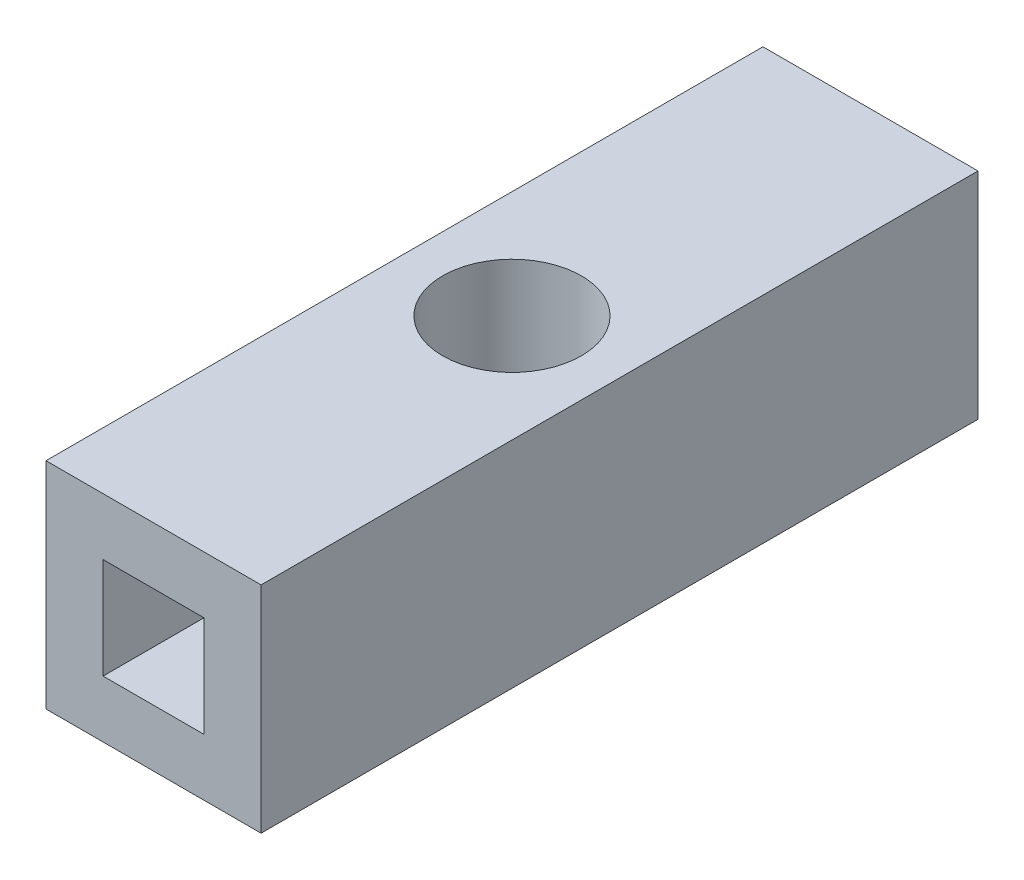
from build123d import *

# Parameters (mm, degrees)
SKETCH2_W               = 7.62
SKETCH2_H               = 7.62
BOSS_EXTRUDE1_DEPTH     = 12.7
F_8_CLEARANCE_HOLE1_D   = 4.9149
CUT_EXTRUDE1_REACH      = 27.965
CUT_EXTRUDE1_END_RADIUS = 3.47345
SKETCH5_W               = 3.175
SKETCH5_H               = 3.175
CUT_EXTRUDE2_REACH      = 27.965
CUT_EXTRUDE2_END_RADIUS = 3.47345
CUT_EXTRUDE3_REACH      = 27.965
CUT_EXTRUDE3_END_RADIUS = 3.47345
SKETCH7_W               = 3.575
SKETCH7_H               = 3.575
SKETCH7_W_2             = 3.175
SKETCH7_H_2             = 3.175
CUT_EXTRUDE4_REACH      = 27.965
CUT_EXTRUDE4_END_RADIUS = 3.47345


with BuildPart() as part:
    # Sketch2 → Boss-Extrude1 (new, symmetric)
    with BuildSketch(Plane.XY):
        Rectangle(SKETCH2_W, SKETCH2_H)
    extrude(amount=BOSS_EXTRUDE1_DEPTH, both=True)

    # #8 Clearance Hole1 (through all)
    with Locations(Plane(origin=(0, 3.81, 0), x_dir=(1, 0, 0), z_dir=(0, 1, 0))):
        with Locations((0, 0)):
            Hole(F_8_CLEARANCE_HOLE1_D / 2)

    # Cut-Extrude1: up to this cylinder (the profile starts outside it)
    cut_extrude1_end = Plane(origin=(0, 0, 0), z_dir=(0, 1, 0)) * Cylinder(CUT_EXTRUDE1_END_RADIUS, 63.8769, mode=Mode.PRIVATE)
    # Sketch5 → Cut-Extrude1 (cut, up to the surface)
    with BuildSketch(Plane.XY.offset(12.7), mode=Mode.PRIVATE) as cut_extrude1_sk1:
        Rectangle(SKETCH5_W, SKETCH5_H)
    cut_extrude1_tool1 = extrude(cut_extrude1_sk1.sketch, amount=-CUT_EXTRUDE1_REACH, mode=Mode.PRIVATE) - cut_extrude1_end
    add(cut_extrude1_tool1.solids().sort_by_distance((0, 0, 12.7))[0], mode=Mode.SUBTRACT)

    # Cut-Extrude2: up to this cylinder (the profile starts outside it)
    cut_extrude2_end = Plane(origin=(0, 0, 0), z_dir=(0, 1, 0)) * Cylinder(CUT_EXTRUDE2_END_RADIUS, 63.8769, mode=Mode.PRIVATE)
    # Sketch6 → Cut-Extrude2 (cut, up to the surface)
    with BuildSketch(Plane(origin=(0, 0, -12.7), x_dir=(-1, 0, 0), z_dir=(0, 0, -1)), mode=Mode.PRIVATE) as cut_extrude2_sk1:
        with BuildLine():
            Line((1.499999936, 1.322875825), (1.499999936, -1.322875825))
            ThreePointArc((1.499999936, -1.322875825), (-2.000000064, 0), (1.499999936, 1.322875825))
        make_face()
    cut_extrude2_tool1 = extrude(cut_extrude2_sk1.sketch, amount=-CUT_EXTRUDE2_REACH, mode=Mode.PRIVATE) - cut_extrude2_end
    add(cut_extrude2_tool1.solids().sort_by_distance((0.132366, 0, -12.7))[0], mode=Mode.SUBTRACT)

    # Cut-Extrude3: up to this cylinder (the profile starts outside it)
    cut_extrude3_end = Plane(origin=(0, 0, 0), z_dir=(0, 1, 0)) * Cylinder(CUT_EXTRUDE3_END_RADIUS, 63.8769, mode=Mode.PRIVATE)
    # Sketch7 → Cut-Extrude3 (cut, up to the surface)
    with BuildSketch(Plane.XY.offset(12.7), mode=Mode.PRIVATE) as cut_extrude3_sk1:
        Rectangle(SKETCH7_W, SKETCH7_H)
        Rectangle(SKETCH7_W_2, SKETCH7_H_2, mode=Mode.SUBTRACT)
    cut_extrude3_tool1 = extrude(cut_extrude3_sk1.sketch, amount=-CUT_EXTRUDE3_REACH, mode=Mode.PRIVATE) - cut_extrude3_end
    add(cut_extrude3_tool1.solids().sort_by_distance((-1.736942, 0, 12.7))[0], mode=Mode.SUBTRACT)

    # Cut-Extrude4: up to this cylinder (the profile starts outside it)
    cut_extrude4_end = Plane(origin=(0, 0, 0), z_dir=(0, 1, 0)) * Cylinder(CUT_EXTRUDE4_END_RADIUS, 63.8769, mode=Mode.PRIVATE)
    # Sketch8 → Cut-Extrude4 (cut, up to the surface)
    with BuildSketch(Plane(origin=(0, 0, -12.7), x_dir=(-1, 0, 0), z_dir=(0, 0, -1)), mode=Mode.PRIVATE) as cut_extrude4_sk1:
        with BuildLine():
            Line((1.699999936, -1.396424183), (1.699999936, 1.396424183))
            ThreePointArc((1.699999936, 1.396424183), (-2.200000064, 0), (1.699999936, -1.396424183))
        make_face()
    cut_extrude4_tool1 = extrude(cut_extrude4_sk1.sketch, amount=-CUT_EXTRUDE4_REACH, mode=Mode.PRIVATE) - cut_extrude4_end
    add(cut_extrude4_tool1.solids().sort_by_distance((0.127385, 0, -12.7))[0], mode=Mode.SUBTRACT)


solid = part.part
